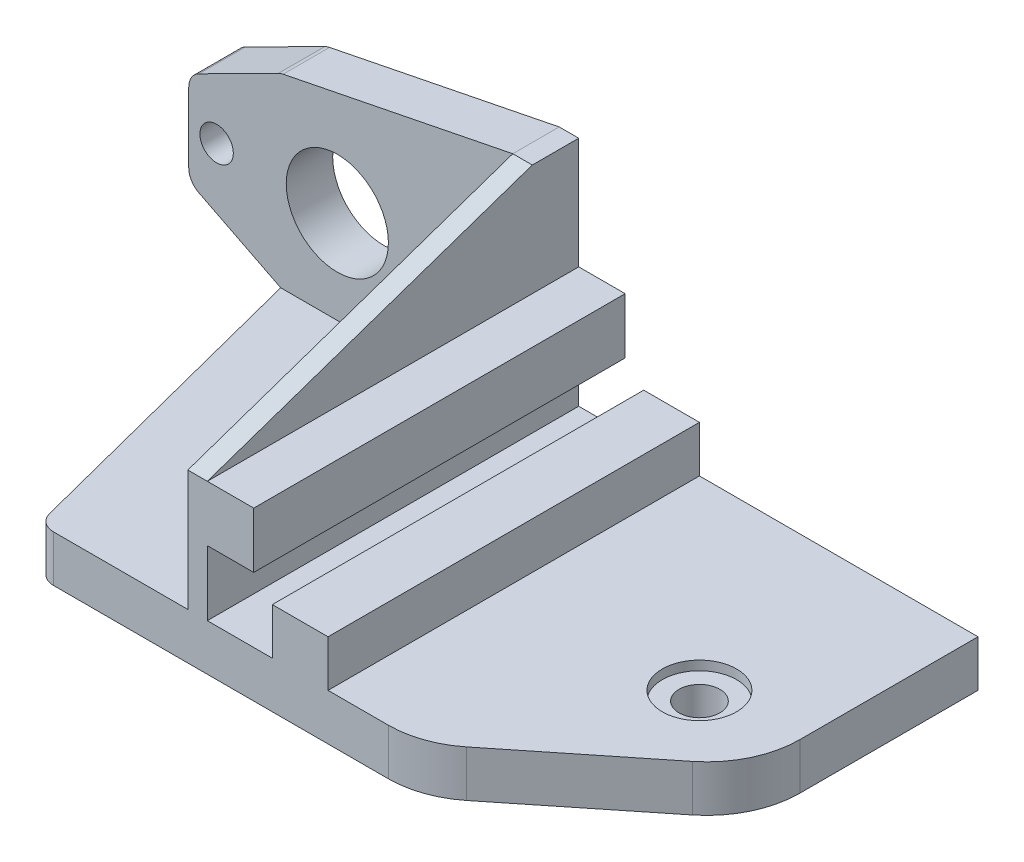
from build123d import *

# Parameters (mm, degrees)
ESQUISSE1_W              = 50
ESQUISSE1_H              = 30
BOSS_EXTRU_1_DEPTH       = 40
ESQUISSE2_W              = 7
ESQUISSE2_H              = 7
ENL_V_MAT_EXTRU_1_DEPTH  = 41
ESQUISSE3_W              = 8
ESQUISSE3_H              = 10
ENL_V_MAT_EXTRU_2_DEPTH  = 41
ESQUISSE5_W              = 34.9
ESQUISSE5_H              = 30
ENL_V_MAT_EXTRU_4_DEPTH  = 35
ESQUISSE7_R              = 5.5
ESQUISSE7_R_2            = 1.8
ENL_V_MAT_EXTRU_6_DEPTH  = 41
BOSS_EXTRU_2_DEPTH       = 5
ESQUISSE10_R             = 2.1
ENL_V_MAT_EXTRU_7_DEPTH  = 31
ESQUISSE11_R             = 4
ENL_V_MAT_EXTRU_8_DEPTH  = 1
ENL_V_MAT_EXTRU_9_DEPTH  = 6
CONG_2_R                 = 2
ESQUISSE14_W             = 13
ESQUISSE14_H             = 12
ENL_V_MAT_EXTRU_10_DEPTH = 41
ESQUISSE15_W             = 40
ESQUISSE15_H             = 5
BOSS_EXTRU_3_DEPTH       = 30
ESQUISSE16_R             = 2.2
ENL_V_MAT_EXTRU_11_DEPTH = 6
ESQUISSE17_R             = 4
ENL_V_MAT_EXTRU_12_DEPTH = 1
CHANFREIN1_SIZE          = 20
CHANFREIN1_SIZE2         = 16
CONG_3_R                 = 10
CHANFREIN2_SIZE          = 35
CHANFREIN2_SIZE2         = 12
CONG_4_R                 = 10


with BuildPart() as part:
    # Esquisse1 → Boss.-Extru.1 (new body)
    with BuildSketch(Plane.XY):
        Rectangle(ESQUISSE1_W, ESQUISSE1_H)
    extrude(amount=BOSS_EXTRU_1_DEPTH)

    # Esquisse2 → Enlèv. mat.-Extru.1 (cut, through all)
    with BuildSketch(Plane.XY.offset(40)):
        with Locations((15.5, -6.5)):
            Rectangle(ESQUISSE2_W, ESQUISSE2_H)
        with Locations((15.5, 6.5)):
            Rectangle(ESQUISSE2_W, ESQUISSE2_H)
    extrude(amount=-ENL_V_MAT_EXTRU_1_DEPTH, mode=Mode.SUBTRACT)

    # Esquisse3 → Enlèv. mat.-Extru.2 (cut, through all)
    with BuildSketch(Plane.XY.offset(40)):
        with Locations((21, 0)):
            Rectangle(ESQUISSE3_W, ESQUISSE3_H)
    extrude(amount=-ENL_V_MAT_EXTRU_2_DEPTH, mode=Mode.SUBTRACT)

    # Esquisse5 → Enlèv. mat.-Extru.4 (cut)
    with BuildSketch(Plane.XY.offset(40)):
        with Locations((-7.55, 0)):
            Rectangle(ESQUISSE5_W, ESQUISSE5_H)
    extrude(amount=-ENL_V_MAT_EXTRU_4_DEPTH, mode=Mode.SUBTRACT)

    # Esquisse7 → Enlèv. mat.-Extru.6 (cut, through all)
    with BuildSketch(Plane(origin=(0, 0, 0), x_dir=(-1, 0, 0), z_dir=(0, 0, -1))):
        with Locations((9, 0)):
            Circle(ESQUISSE7_R)
        with Locations((22, 0)):
            Circle(ESQUISSE7_R_2)
        with Locations((-4, 0)):
            Circle(ESQUISSE7_R_2)
    extrude(amount=-ENL_V_MAT_EXTRU_6_DEPTH, mode=Mode.SUBTRACT)

    # Esquisse9 → Boss.-Extru.2 (add)
    with BuildSketch(Plane.XZ.offset(15)):
        Polygon((9.9, 40), (-6.1, 40), (-15.1, 5), (9.9, 5), align=None)
    extrude(amount=-BOSS_EXTRU_2_DEPTH)

    # Esquisse10 → Enlèv. mat.-Extru.7 (cut, through all)
    with BuildSketch(Plane.XZ.offset(15)):
        with Locations((5, 20)):
            Circle(ESQUISSE10_R)
    extrude(amount=-ENL_V_MAT_EXTRU_7_DEPTH, mode=Mode.SUBTRACT)

    # Esquisse11 → Enlèv. mat.-Extru.8 (cut)
    with BuildSketch(Plane(origin=(0, -10, 0), x_dir=(1, 0, 0), z_dir=(0, 1, 0))):
        with Locations((5, -20)):
            Circle(ESQUISSE11_R)
    extrude(amount=-ENL_V_MAT_EXTRU_8_DEPTH, mode=Mode.SUBTRACT)

    # Esquisse13 → Enlèv. mat.-Extru.9 (cut, through all)
    with BuildSketch(Plane.XY.offset(5)):
        Polygon((-15.1, -15), (-15.1, -10), (-25, -5), (-25, -15), align=None)
        Polygon((-25, 5), (-15.1, 10), (9.9, 15), (-25, 15), align=None)
    extrude(amount=-ENL_V_MAT_EXTRU_9_DEPTH, mode=Mode.SUBTRACT)

    # Congé2
    cong_2_edges = [part.edges().sort_by_distance(p)[0] for p in [
        (-6.1, -12.5, 40),
        (-25, -5, 2.5),
        (-25, 5, 2.5),
        (-15.1, 10, 2.5),
    ]]
    fillet(cong_2_edges, radius=CONG_2_R)

    # Esquisse14 → Enlèv. mat.-Extru.10 (cut, through all)
    with BuildSketch(Plane.XY.offset(40)):
        with Locations((18.5, 9)):
            Rectangle(ESQUISSE14_W, ESQUISSE14_H)
    extrude(amount=-ENL_V_MAT_EXTRU_10_DEPTH, mode=Mode.SUBTRACT)

    # Esquisse15 → Boss.-Extru.3 (add)
    with BuildSketch(Plane(origin=(25, 0, 0), x_dir=(0, 0, -1), z_dir=(1, 0, 0))):
        with Locations((-20, -12.5)):
            Rectangle(ESQUISSE15_W, ESQUISSE15_H)
    extrude(amount=BOSS_EXTRU_3_DEPTH)

    # Esquisse16 → Enlèv. mat.-Extru.11 (cut, through all)
    with BuildSketch(Plane(origin=(0, -10, 0), x_dir=(1, 0, 0), z_dir=(0, 1, 0))):
        with Locations((45, -20)):
            Circle(ESQUISSE16_R)
    extrude(amount=-ENL_V_MAT_EXTRU_11_DEPTH, mode=Mode.SUBTRACT)

    # Esquisse17 → Enlèv. mat.-Extru.12 (cut)
    with BuildSketch(Plane(origin=(0, -10, 0), x_dir=(1, 0, 0), z_dir=(0, 1, 0))):
        with Locations((45, -20)):
            Circle(ESQUISSE17_R)
    extrude(amount=-ENL_V_MAT_EXTRU_12_DEPTH, mode=Mode.SUBTRACT)

    # Chanfrein1
    chanfrein1_edges = [part.edges().sort_by_distance(p)[0] for p in [
        (55, -12.5, 40),
    ]]
    chanfrein1_side = [part.faces().sort_by_distance(p)[0] for p in [
        (22.378363324, -9.30070091, 40),
    ]]
    chamfer(chanfrein1_edges, length=CHANFREIN1_SIZE, length2=CHANFREIN1_SIZE2, reference=chanfrein1_side[0])

    # Congé3
    cong_3_edges = [part.edges().sort_by_distance(p)[0] for p in [
        (55, -12.5, 24),
    ]]
    fillet(cong_3_edges, radius=CONG_3_R)

    # Chanfrein2
    chanfrein2_edges = [part.edges().sort_by_distance(p)[0] for p in [
        (10.95, 15, 40),
    ]]
    chanfrein2_side = [part.faces().sort_by_distance(p)[0] for p in [
        (10.95, 15, 20),
    ]]
    chamfer(chanfrein2_edges, length=CHANFREIN2_SIZE, length2=CHANFREIN2_SIZE2, reference=chanfrein2_side[0])

    # Congé4
    cong_4_edges = [part.edges().sort_by_distance(p)[0] for p in [
        (35, -12.5, 40),
    ]]
    fillet(cong_4_edges, radius=CONG_4_R)


solid = part.part
